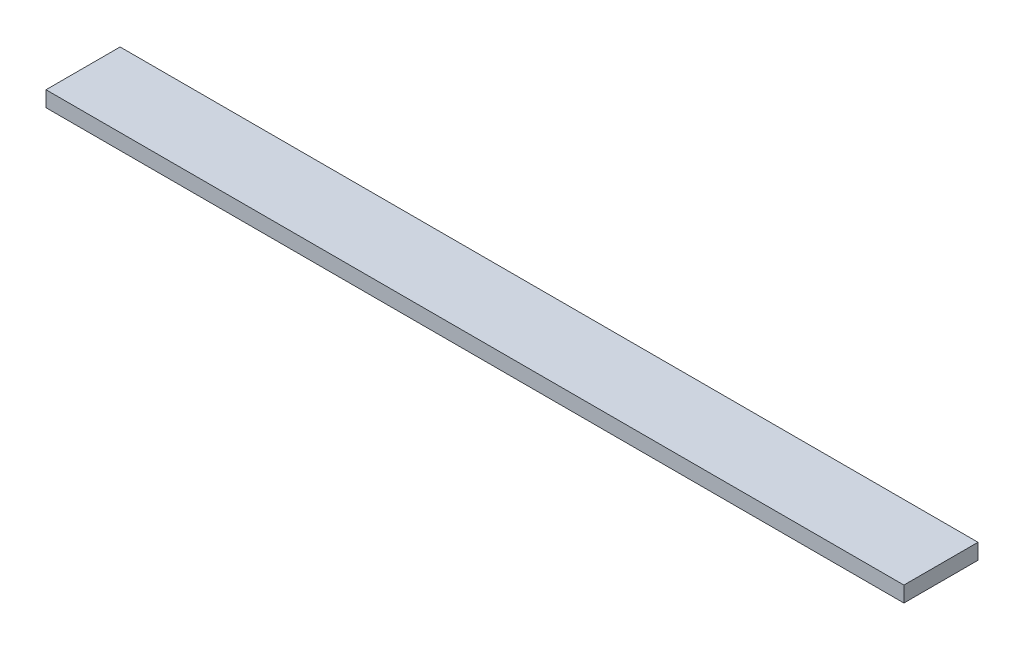
from build123d import *

# Parameters (mm, degrees)
SKETCH1_W           = 139.7
SKETCH1_H           = 12.065
BOSS_EXTRUDE1_DEPTH = 2.54


with BuildPart() as part:
    # Sketch1 → Boss-Extrude1 (new body)
    with BuildSketch(Plane(origin=(0, 0, 0), x_dir=(1, 0, 0), z_dir=(0, 1, 0))):
        with Locations((69.85, 6.0325)):
            Rectangle(SKETCH1_W, SKETCH1_H)
    extrude(amount=BOSS_EXTRUDE1_DEPTH)


solid = part.part
